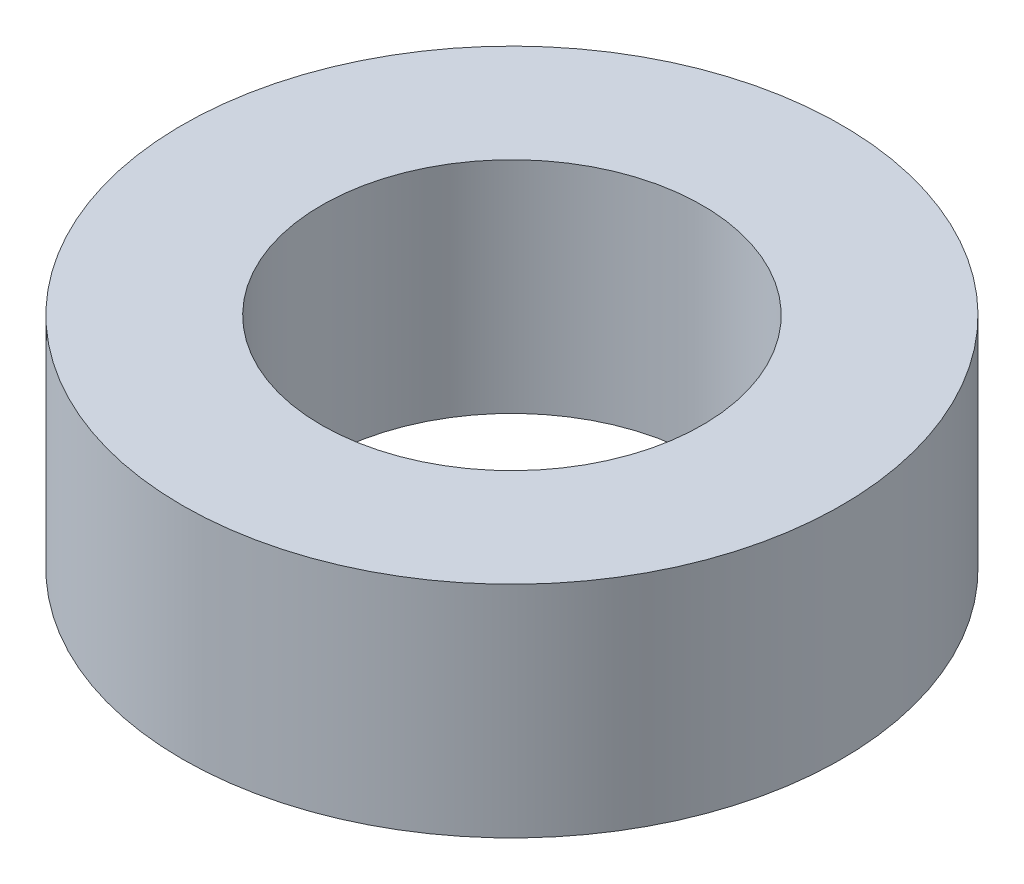
from build123d import *

# Parameters (mm, degrees)
SKETCH_1_R      = 22.5
SKETCH_1_R_2    = 13
EXTRUDE_1_DEPTH = 15


with BuildPart() as part:
    # 草图1 → 凸台-拉伸1 (new body)
    with BuildSketch(Plane(origin=(0, 0, 0), x_dir=(1, 0, 0), z_dir=(0, 1, 0))):
        Circle(SKETCH_1_R)
        Circle(SKETCH_1_R_2, mode=Mode.SUBTRACT)
    extrude(amount=EXTRUDE_1_DEPTH)


solid = part.part
